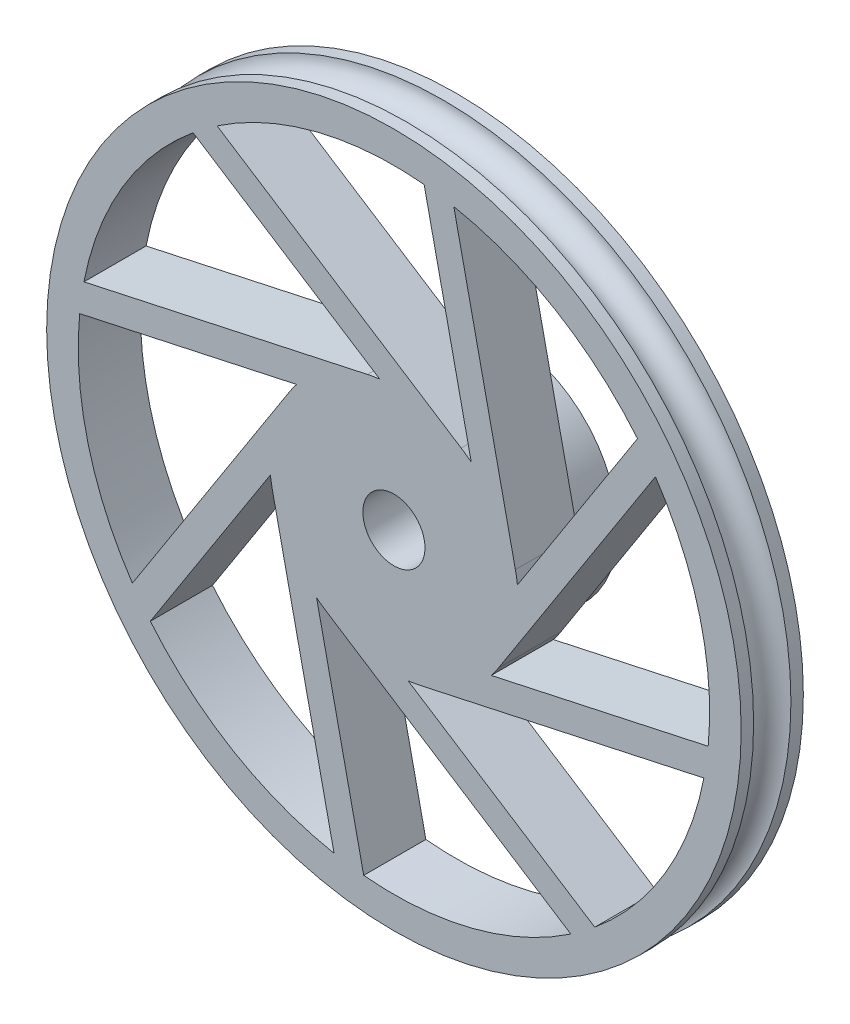
from build123d import *

# Parameters (mm, degrees)
SKETCH1_R           = 27.94
BOSS_EXTRUDE1_DEPTH = 5
CUT_EXTRUDE2_DEPTH  = 5
SKETCH9_R           = 1.5
SKETCH10_R          = 9
BOSS_EXTRUDE2_DEPTH = 4
CUT_EXTRUDE4_DEPTH  = 4
SKETCH12_R          = 2.5
CUT_EXTRUDE5_DEPTH  = 6


with BuildPart() as part:
    # Sketch1 → Boss-Extrude1 (new body)
    with BuildSketch(Plane.XY):
        Circle(SKETCH1_R)
    extrude(amount=-BOSS_EXTRUDE1_DEPTH)

    # Sketch7 → Cut-Extrude2 (cut)
    with BuildSketch(Plane.XY):
        with BuildLine():
            ThreePointArc((2.122364529, -9.772183421), (1.630852156, -9.866119868), (1.135255991, -9.935350715))
            Line((1.135255991, -9.935350715), (16.158618381, -19.597424627))
            ThreePointArc((16.158618381, -19.597424627), (21.837418082, -12.972554549), (24.939104938, -4.816746297))
            Line((24.939104938, -4.816746297), (2.122364529, -9.772183421))
        make_face()
        with BuildLine():
            Line((14.228656248, -21.040564188), (-5.409238814, -8.410715514))
            ThreePointArc((-5.409238814, -8.410715514), (-5.823213644, -8.129586881), (-6.222606654, -7.828101074))
            Line((-6.222606654, -7.828101074), (-2.431603216, -25.283340479))
            ThreePointArc((-2.431603216, -25.283340479), (6.268405118, -24.6143677), (14.228656248, -21.040564188))
        make_face()
        with BuildLine():
            ThreePointArc((8.410715514, -5.409238814), (8.129586881, -5.823213644), (7.828101074, -6.222606654))
            Line((7.828101074, -6.222606654), (25.283340479, -2.431603216))
            ThreePointArc((25.283340479, -2.431603216), (24.6143677, 6.268405118), (21.040564188, 14.228656248))
            Line((21.040564188, 14.228656248), (8.410715514, -5.409238814))
        make_face()
        with BuildLine():
            Line((-4.816746297, -24.939104938), (-9.772183421, -2.122364529))
            ThreePointArc((-9.772183421, -2.122364529), (-9.866119868, -1.630852156), (-9.935350715, -1.135255991))
            Line((-9.935350715, -1.135255991), (-19.597424627, -16.158618381))
            ThreePointArc((-19.597424627, -16.158618381), (-12.972554549, -21.837418082), (-4.816746297, -24.939104938))
        make_face()
        with BuildLine():
            Line((-21.040564188, -14.228656248), (-8.410715514, 5.409238814))
            ThreePointArc((-8.410715514, 5.409238814), (-8.129586881, 5.823213644), (-7.828101074, 6.222606654))
            Line((-7.828101074, 6.222606654), (-25.283340479, 2.431603216))
            ThreePointArc((-25.283340479, 2.431603216), (-24.6143677, -6.268405118), (-21.040564188, -14.228656248))
        make_face()
        with BuildLine():
            Line((9.935350715, 1.135255991), (19.597424627, 16.158618381))
            ThreePointArc((19.597424627, 16.158618381), (12.972554549, 21.837418082), (4.816746297, 24.939104938))
            Line((4.816746297, 24.939104938), (9.772183421, 2.122364529))
            ThreePointArc((9.772183421, 2.122364529), (9.866119868, 1.630852156), (9.935350715, 1.135255991))
        make_face()
        with BuildLine():
            Line((-24.939104938, 4.816746297), (-2.122364529, 9.772183421))
            ThreePointArc((-2.122364529, 9.772183421), (-1.630852156, 9.866119868), (-1.135255991, 9.935350715))
            Line((-1.135255991, 9.935350715), (-16.158618381, 19.597424627))
            ThreePointArc((-16.158618381, 19.597424627), (-21.837418082, 12.972554549), (-24.939104938, 4.816746297))
        make_face()
        with BuildLine():
            Line((6.222606654, 7.828101074), (2.431603216, 25.283340479))
            ThreePointArc((2.431603216, 25.283340479), (-6.268405118, 24.6143677), (-14.228656248, 21.040564188))
            Line((-14.228656248, 21.040564188), (5.409238814, 8.410715514))
            ThreePointArc((5.409238814, 8.410715514), (5.823213644, 8.129586881), (6.222606654, 7.828101074))
        make_face()
    extrude(amount=-CUT_EXTRUDE2_DEPTH, mode=Mode.SUBTRACT)

    # Sketch9 → Cut-Revolve3 (revolve, cut)
    with BuildSketch(Plane(origin=(0, 0, 0), x_dir=(1, 0, 0), z_dir=(0, 1, 0))):
        with Locations((-27.94, 2.5)):
            Circle(SKETCH9_R)
    revolve(axis=Axis((0, 0, -92.148103423), (0, 0, 1)), mode=Mode.SUBTRACT)

    # Sketch10 → Boss-Extrude2 (add)
    with BuildSketch(Plane(origin=(0, 0, -5), x_dir=(-1, 0, 0), z_dir=(0, 0, -1))):
        Circle(SKETCH10_R)
    extrude(amount=BOSS_EXTRUDE2_DEPTH)

    # Sketch11 → Cut-Extrude4 (cut)
    with BuildSketch(Plane(origin=(0, 0, -9), x_dir=(-1, 0, 0), z_dir=(0, 0, -1))):
        Polygon((7, 0), (3.5, 6.062177826), (-3.5, 6.062177826), (-7, 0), (-3.5, -6.062177826), (3.5, -6.062177826), align=None)
    extrude(amount=-CUT_EXTRUDE4_DEPTH, mode=Mode.SUBTRACT)

    # Sketch12 → Cut-Extrude5 (cut, through all)
    with BuildSketch(Plane(origin=(0, 0, -5), x_dir=(-1, 0, 0), z_dir=(0, 0, -1))):
        Circle(SKETCH12_R)
    extrude(amount=-CUT_EXTRUDE5_DEPTH, mode=Mode.SUBTRACT)


solid = part.part
